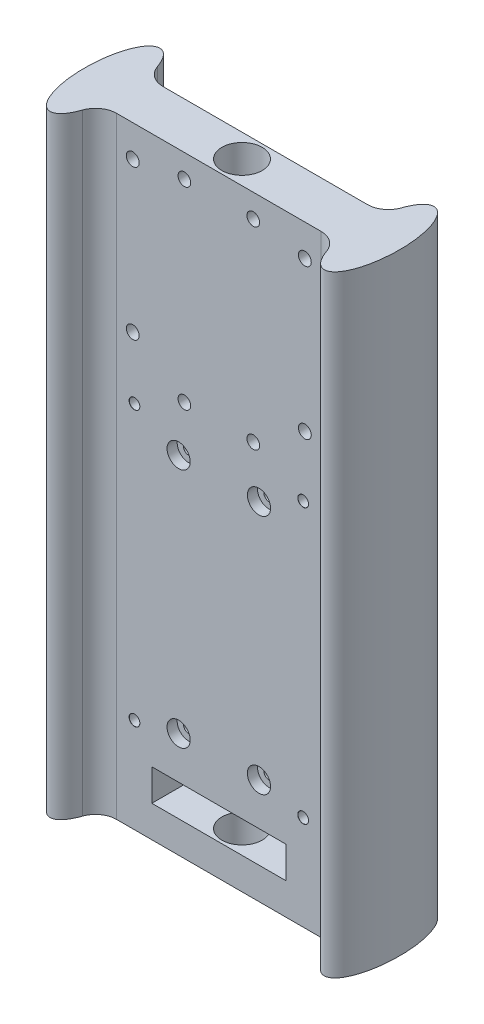
from build123d import *

# Parameters (mm, degrees)
SKETCH1_RX                        = 13
SKETCH1_RY                        = 4.85
SKETCH1_W                         = 65
SKETCH1_H                         = 11
SKETCH1_R                         = 4.7775
BOSS_EXTRUDE1_DEPTH               = 145
FILLET1_R                         = 5
SKETCH3_W                         = 31.75
SKETCH3_H                         = 7.5
CUT_EXTRUDE2_DEPTH                = 8.5000001
CUT_EXTRUDE2_DEPTH_BACK           = 19.5000001
TAP_DRILL_FOR_M3X0_5_TAP1_D       = 2.5
SKETCH6_R                         = 2.75
CUT_EXTRUDE4_DEPTH                = 2.4
TAP_DRILL_FOR_M3_TAP1_D           = 2.5
TAP_DRILL_FOR_M3_TAP1_CSINK_D     = 2.55
TAP_DRILL_FOR_M3_TAP1_CSINK_ANGLE = 90
SKETCH9_R                         = 1.5
CUT_EXTRUDE5_DEPTH                = 19.5000001
CUT_EXTRUDE6_REACH                = 20.5
SKETCH5_R                         = 1.525


with BuildPart() as part:
    # Sketch1 → Boss-Extrude1 (new body)
    with BuildSketch(Plane(origin=(0, 0, 0), x_dir=(1, 0, 0), z_dir=(0, 1, 0))):
        with Locations(Location((-32.5, 0), (0, 0, -90))):
            Ellipse(SKETCH1_RX, SKETCH1_RY)
        with Locations(Location((32.5, 0), (0, 0, 90))):
            Ellipse(SKETCH1_RX, SKETCH1_RY)
        Rectangle(SKETCH1_W, SKETCH1_H)
        Circle(SKETCH1_R, mode=Mode.SUBTRACT)
    extrude(amount=BOSS_EXTRUDE1_DEPTH)

    # Fillet1
    fillet1_edges = [part.edges().sort_by_distance(p)[0] for p in [
        (-28.105445223, 72.5, -5.5),
        (28.105445223, 72.5, -5.5),
        (28.105445223, 72.5, 5.5),
        (-28.105445223, 72.5, 5.5),
    ]]
    fillet(fillet1_edges, radius=FILLET1_R)

    # Sketch3 → Cut-Extrude2 (cut, two sides)
    with BuildSketch(Plane(origin=(0, 0, -5.5), x_dir=(-1, 0, 0), z_dir=(0, 0, -1))) as cut_extrude2_sk:
        with Locations((0, 11.25)):
            Rectangle(SKETCH3_W, SKETCH3_H)
    extrude(amount=CUT_EXTRUDE2_DEPTH, mode=Mode.SUBTRACT)
    extrude(cut_extrude2_sk.sketch, amount=-CUT_EXTRUDE2_DEPTH_BACK, mode=Mode.SUBTRACT)

    # Tap Drill for M3x0.5 Tap1 (through all)
    with Locations(Plane(origin=(9.525, 82.15, -5.5), x_dir=(-1, 0, 0), z_dir=(0, 0, -1))):
        with Locations((0, 0), (19.05, 0), (19.05, -57.15), (0, -57.15)):
            Hole(TAP_DRILL_FOR_M3X0_5_TAP1_D / 2)

    # Sketch6 → Cut-Extrude4 (cut)
    with BuildSketch(Plane.XY.offset(5.5)):
        with Locations((9.525, 82.15)):
            Circle(SKETCH6_R)
        with Locations((-9.525, 82.15)):
            Circle(SKETCH6_R)
        with Locations((9.525, 25)):
            Circle(SKETCH6_R)
        with Locations((-9.525, 25)):
            Circle(SKETCH6_R)
    extrude(amount=-CUT_EXTRUDE4_DEPTH, mode=Mode.SUBTRACT)

    # Tap Drill for M3 Tap1 (through all)
    with Locations(Plane.XY.offset(5.5)):
        with Locations((-20, 87.5), (20, 87.5), (20, 22.5), (-20, 22.5)):
            CounterSinkHole(TAP_DRILL_FOR_M3_TAP1_D / 2, TAP_DRILL_FOR_M3_TAP1_CSINK_D / 2, counter_sink_angle=TAP_DRILL_FOR_M3_TAP1_CSINK_ANGLE)

    # Sketch9 → Cut-Extrude5 (cut, through all)
    with BuildSketch(Plane(origin=(0, 0, -5.5), x_dir=(-1, 0, 0), z_dir=(0, 0, -1))):
        with Locations((-8.168, 139.5)):
            Circle(SKETCH9_R)
        with Locations((8.168, 139.5)):
            Circle(SKETCH9_R)
        with Locations((8.168, 93.7)):
            Circle(SKETCH9_R)
        with Locations((-8.168, 93.7)):
            Circle(SKETCH9_R)
    extrude(amount=-CUT_EXTRUDE5_DEPTH, mode=Mode.SUBTRACT)

    # Sketch5 → Cut-Extrude6 (cut, up to next)
    with BuildSketch(Plane.XY.offset(5.5), mode=Mode.PRIVATE) as cut_extrude6_sk1:
        with Locations((20.4, 102)):
            Circle(SKETCH5_R)
    cut_extrude6_tool1 = extrude(cut_extrude6_sk1.sketch, amount=-CUT_EXTRUDE6_REACH, mode=Mode.PRIVATE) & part.part
    add(cut_extrude6_tool1.solids().sort_by_distance((20.4, 102, 5.5))[0], mode=Mode.SUBTRACT)
    # Sketch5 → Cut-Extrude6 (cut, up to next)
    with BuildSketch(Plane.XY.offset(5.5), mode=Mode.PRIVATE) as cut_extrude6_sk2:
        with Locations((-20.4, 102)):
            Circle(SKETCH5_R)
    cut_extrude6_tool2 = extrude(cut_extrude6_sk2.sketch, amount=-CUT_EXTRUDE6_REACH, mode=Mode.PRIVATE) & part.part
    add(cut_extrude6_tool2.solids().sort_by_distance((-20.4, 102, 5.5))[0], mode=Mode.SUBTRACT)
    # Sketch5 → Cut-Extrude6 (cut, up to next)
    with BuildSketch(Plane.XY.offset(5.5), mode=Mode.PRIVATE) as cut_extrude6_sk3:
        with Locations((20.4, 137.5)):
            Circle(SKETCH5_R)
    cut_extrude6_tool3 = extrude(cut_extrude6_sk3.sketch, amount=-CUT_EXTRUDE6_REACH, mode=Mode.PRIVATE) & part.part
    add(cut_extrude6_tool3.solids().sort_by_distance((20.4, 137.5, 5.5))[0], mode=Mode.SUBTRACT)
    # Sketch5 → Cut-Extrude6 (cut, up to next)
    with BuildSketch(Plane.XY.offset(5.5), mode=Mode.PRIVATE) as cut_extrude6_sk4:
        with Locations((-20.4, 137.5)):
            Circle(SKETCH5_R)
    cut_extrude6_tool4 = extrude(cut_extrude6_sk4.sketch, amount=-CUT_EXTRUDE6_REACH, mode=Mode.PRIVATE) & part.part
    add(cut_extrude6_tool4.solids().sort_by_distance((-20.4, 137.5, 5.5))[0], mode=Mode.SUBTRACT)


solid = part.part
